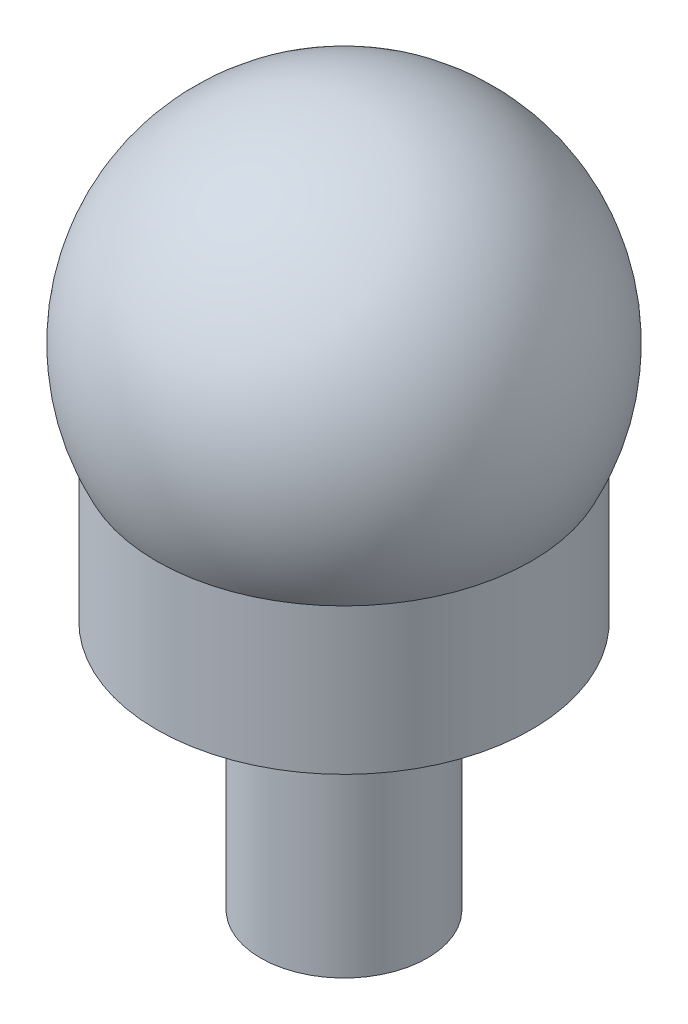
from build123d import *

# Parameters (mm, degrees)
SKETCH1_R           = 4
BOSS_EXTRUDE1_DEPTH = 12
SKETCH3_R           = 9
BOSS_EXTRUDE2_DEPTH = 7


with BuildPart() as part:
    # Sketch1 → Boss-Extrude1 (new body)
    with BuildSketch(Plane(origin=(0, 0, 0), x_dir=(1, 0, 0), z_dir=(0, 1, 0))):
        Circle(SKETCH1_R)
    extrude(amount=BOSS_EXTRUDE1_DEPTH)

    # Sketch3 → Boss-Extrude2 (add)
    with BuildSketch(Plane(origin=(0, 12, 0), x_dir=(1, 0, 0), z_dir=(0, 1, 0))):
        Circle(SKETCH3_R)
    extrude(amount=BOSS_EXTRUDE2_DEPTH)

    # Sketch4 → Revolve2 (revolve)
    with BuildSketch(Plane.XY):
        with BuildLine():
            Line((0, 28.11938617), (0, 19))
            Line((0, 19), (9, 19))
            ThreePointArc((9, 19), (8.596342111, 28.841142067), (0, 33.648835815))
            Line((0, 33.648835815), (0, 28.11938617))
        make_face()
    revolve(axis=Axis((0, 28.11938617, 0), (0, -1, 0)))


solid = part.part
